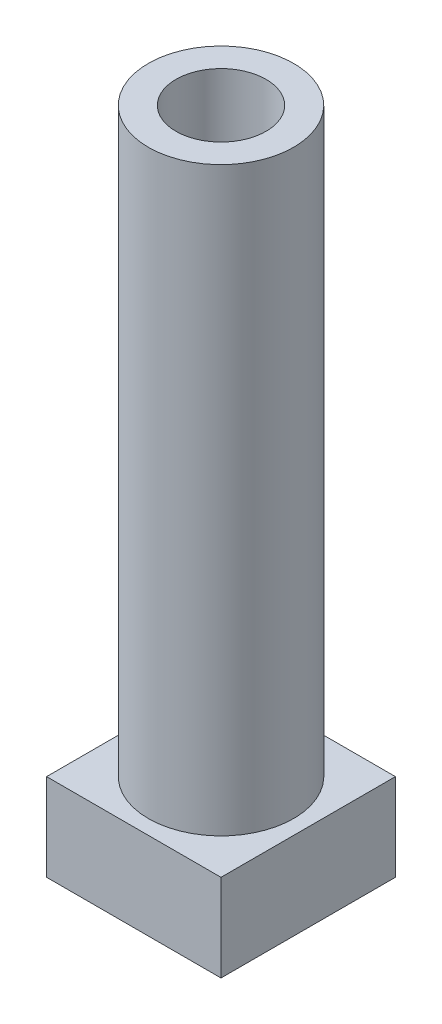
from build123d import *

# Parameters (mm, degrees)
SKETCH1_W           = 6
SKETCH1_H           = 6
BOSS_EXTRUDE1_DEPTH = 3
SKETCH1_3_R         = 1.55
BOSS_EXTRUDE2_DEPTH = 3
SKETCH1_4_R         = 2.5
SKETCH1_4_R_2       = 1.55
BOSS_EXTRUDE3_DEPTH = 20


with BuildPart() as part:
    # Sketch1 → Boss-Extrude1 (new body)
    with BuildSketch(Plane(origin=(0, 0, 0), x_dir=(1, 0, 0), z_dir=(0, 1, 0))):
        Rectangle(SKETCH1_W, SKETCH1_H)
    extrude(amount=-BOSS_EXTRUDE1_DEPTH)

    # Sketch1_3 → Boss-Extrude2 (add)
    with BuildSketch(Plane(origin=(0, 0, 0), x_dir=(1, 0, 0), z_dir=(0, 1, 0))):
        Circle(SKETCH1_3_R)
    extrude(amount=BOSS_EXTRUDE2_DEPTH)

    # Sketch1_4 → Boss-Extrude3 (add)
    with BuildSketch(Plane(origin=(0, 0, 0), x_dir=(1, 0, 0), z_dir=(0, 1, 0))):
        Circle(SKETCH1_4_R)
        Circle(SKETCH1_4_R_2, mode=Mode.SUBTRACT)
    extrude(amount=BOSS_EXTRUDE3_DEPTH)


solid = part.part
